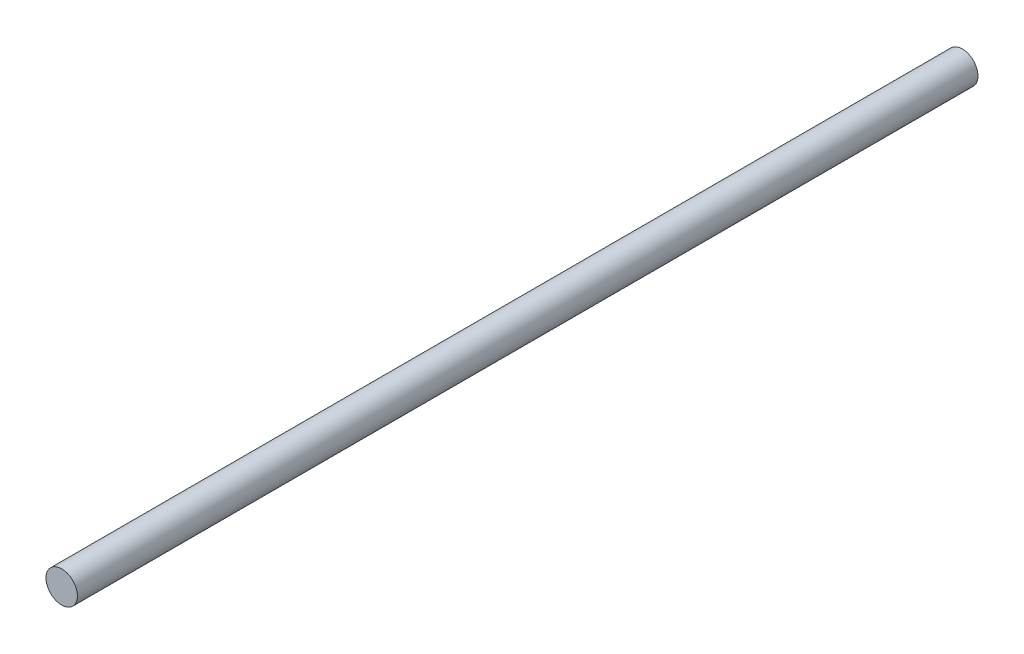
from build123d import *

# Parameters (mm, degrees)
ESQUISSE1_R        = 3
BOSS_EXTRU_1_DEPTH = 172


with BuildPart() as part:
    # Esquisse1 → Boss.-Extru.1 (new body)
    with BuildSketch(Plane.XY):
        Circle(ESQUISSE1_R)
    extrude(amount=BOSS_EXTRU_1_DEPTH)


solid = part.part
